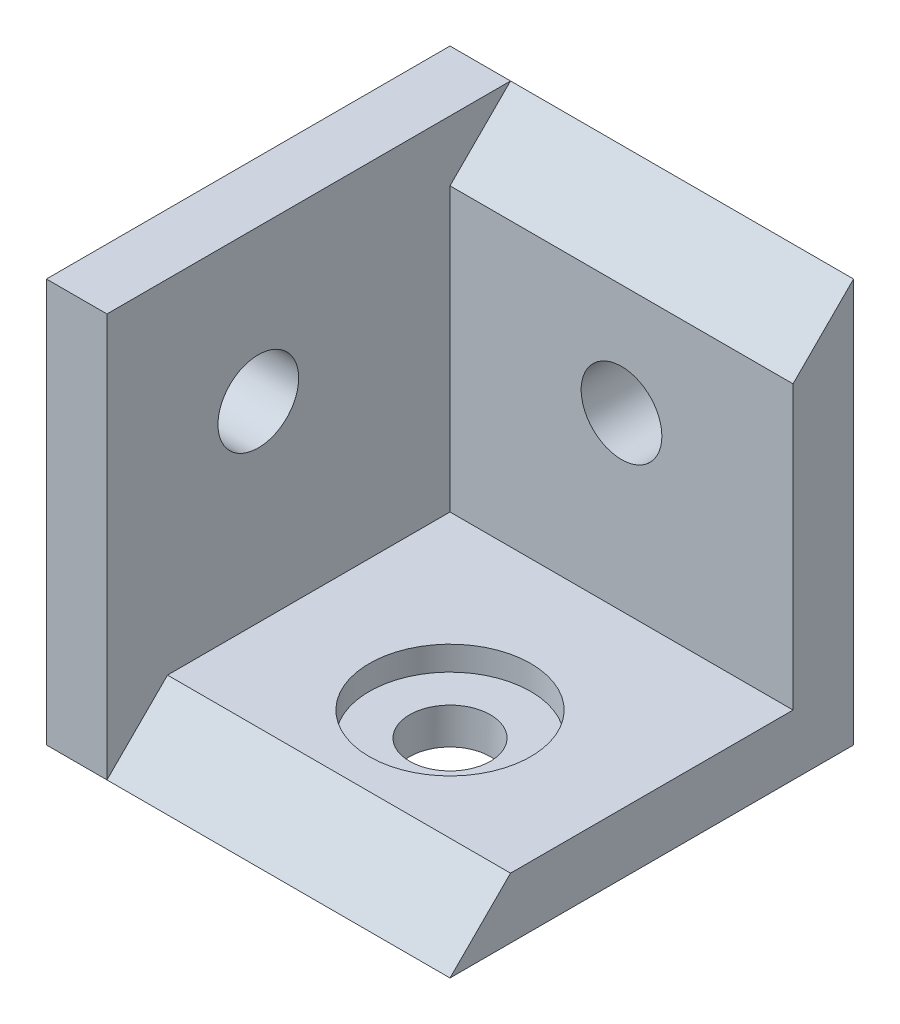
from build123d import *

# Parameters (mm, degrees)
IZIM1_W                     = 20
IZIM1_H                     = 20
Y_KSEKLIK_EKSTR_ZYON1_DEPTH = 20
KES_EKSTR_ZYON1_DEPTH       = 17
IZIM3_W                     = 17.326301073
IZIM3_H                     = 17.919650739
KES_EKSTR_ZYON2_DEPTH       = 17
IZIM6_R                     = 2
KES_EKSTR_ZYON3_DEPTH       = 17
IZIM7_R                     = 2
KES_EKSTR_ZYON4_DEPTH       = 17
IZIM5_R                     = 2
KES_EKSTR_ZYON5_DEPTH       = 17
IZIM8_R                     = 4
KES_EKSTR_ZYON6_DEPTH       = 1.2


with BuildPart() as part:
    # Çizim1 → Yükseklik-Ekstrüzyon1 (new body)
    with BuildSketch(Plane(origin=(0, 0, 0), x_dir=(1, 0, 0), z_dir=(0, 1, 0))):
        with Locations((10, 10)):
            Rectangle(IZIM1_W, IZIM1_H)
    extrude(amount=Y_KSEKLIK_EKSTR_ZYON1_DEPTH)

    # Çizim2 → Kes-Ekstrüzyon1 (cut)
    with BuildSketch(Plane(origin=(20, 0, 0), x_dir=(0, 0, -1), z_dir=(1, 0, 0))):
        Polygon((20, 20), (0, 0), (0, 20), align=None)
    extrude(amount=-KES_EKSTR_ZYON1_DEPTH, mode=Mode.SUBTRACT)

    # Çizim3 → Kes-Ekstrüzyon2 (cut)
    with BuildSketch(Plane(origin=(20, 0, 0), x_dir=(0, 0, -1), z_dir=(1, 0, 0))):
        with Locations((8.336849464, 11.95982537)):
            Rectangle(IZIM3_W, IZIM3_H)
    extrude(amount=-KES_EKSTR_ZYON2_DEPTH, mode=Mode.SUBTRACT)

    # Çizim6 → Kes-Ekstrüzyon3 (cut)
    with BuildSketch(Plane(origin=(3, 0, 0), x_dir=(0, 0, -1), z_dir=(1, 0, 0))):
        with Locations((7.5, 12.5)):
            Circle(IZIM6_R)
    extrude(amount=-KES_EKSTR_ZYON3_DEPTH, mode=Mode.SUBTRACT)

    # Çizim7 → Kes-Ekstrüzyon4 (cut)
    with BuildSketch(Plane.XY.offset(-17)):
        with Locations((11.5, 11.5)):
            Circle(IZIM7_R)
    extrude(amount=-KES_EKSTR_ZYON4_DEPTH, mode=Mode.SUBTRACT)

    # Çizim5 → Kes-Ekstrüzyon5 (cut)
    with BuildSketch(Plane(origin=(0, 3, 0), x_dir=(1, 0, 0), z_dir=(0, 1, 0))):
        with Locations((11.5, 8.5)):
            Circle(IZIM5_R)
    extrude(amount=-KES_EKSTR_ZYON5_DEPTH, mode=Mode.SUBTRACT)

    # Çizim8 → Kes-Ekstrüzyon6 (cut)
    with BuildSketch(Plane(origin=(0, 3, 0), x_dir=(1, 0, 0), z_dir=(0, 1, 0))):
        with Locations((11.5, 8.5)):
            Circle(IZIM8_R)
    extrude(amount=-KES_EKSTR_ZYON6_DEPTH, mode=Mode.SUBTRACT)


solid = part.part
